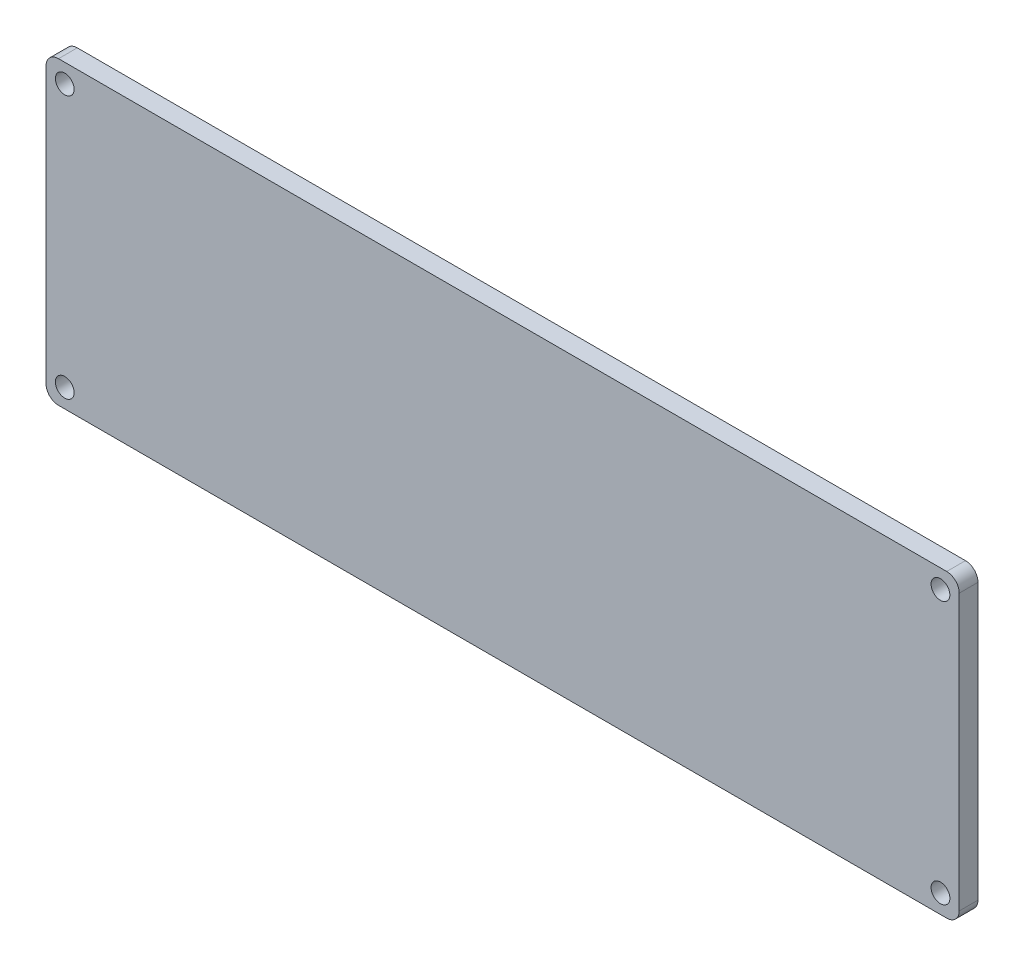
from build123d import *

# Parameters (mm, degrees)
SKETCH1_W           = 146
SKETCH1_H           = 48
SKETCH1_R           = 1.5
BOSS_EXTRUDE1_DEPTH = 3
FILLET1_R           = 2


with BuildPart() as part:
    # Sketch1 → Boss-Extrude1 (new body)
    with BuildSketch(Plane.XY):
        with Locations((73, 24)):
            Rectangle(SKETCH1_W, SKETCH1_H)
        with Locations((3, 45)):
            Circle(SKETCH1_R, mode=Mode.SUBTRACT)
        with Locations((3, 3)):
            Circle(SKETCH1_R, mode=Mode.SUBTRACT)
        with Locations((143, 45)):
            Circle(SKETCH1_R, mode=Mode.SUBTRACT)
        with Locations((143, 3)):
            Circle(SKETCH1_R, mode=Mode.SUBTRACT)
    extrude(amount=BOSS_EXTRUDE1_DEPTH)

    # Fillet1
    fillet1_edges = [part.edges().sort_by_distance(p)[0] for p in [
        (0, 0, 1.5),
        (0, 48, 1.5),
        (146, 48, 1.5),
        (146, 0, 1.5),
    ]]
    fillet(fillet1_edges, radius=FILLET1_R)


solid = part.part
